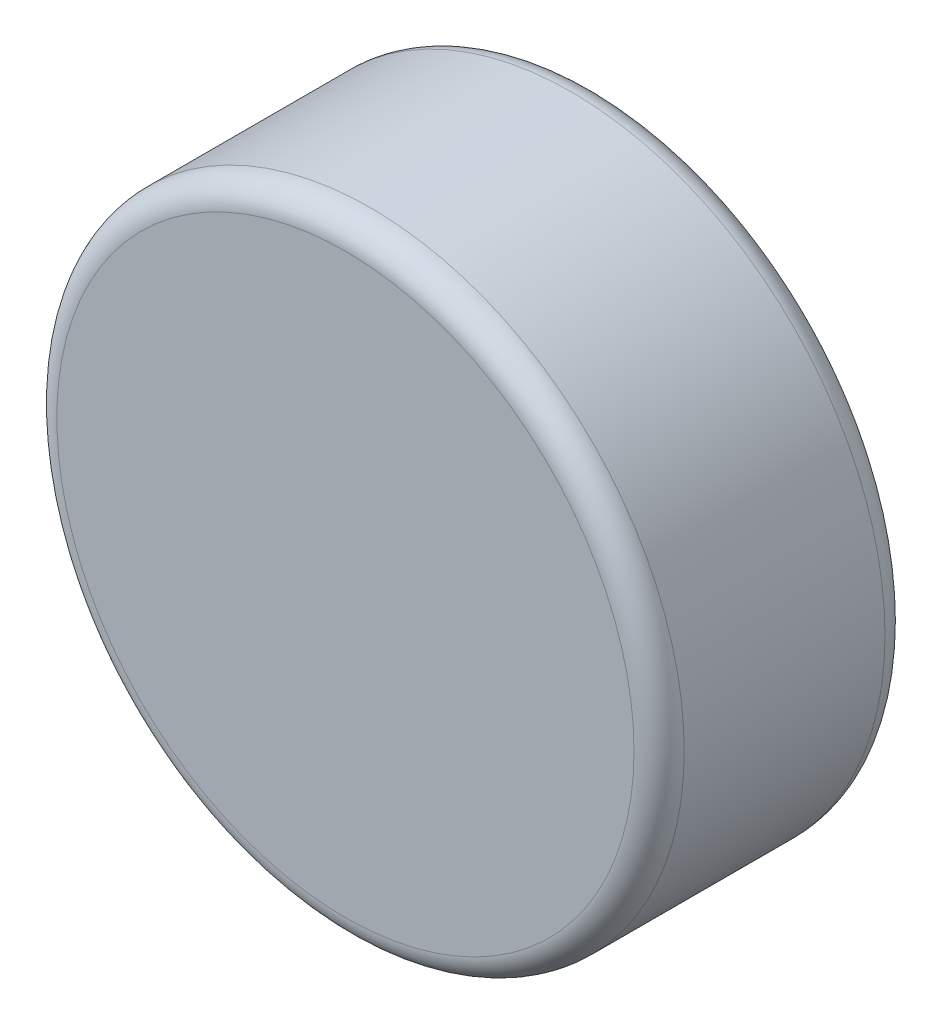
from build123d import *

# Parameters (mm, degrees)
SKETCH1_R           = 2.5
BOSS_EXTRUDE1_DEPTH = 2
FILLET1_R           = 0.2


with BuildPart() as part:
    # Sketch1 → Boss-Extrude1 (new body)
    with BuildSketch(Plane.XY):
        Circle(SKETCH1_R)
    extrude(amount=BOSS_EXTRUDE1_DEPTH)

    # Fillet1
    fillet1_edges = [part.edges().sort_by_distance(p)[0] for p in [
        (-2.5, 0, 0),
        (-2.5, 0, 2),
    ]]
    fillet(fillet1_edges, radius=FILLET1_R)


solid = part.part
